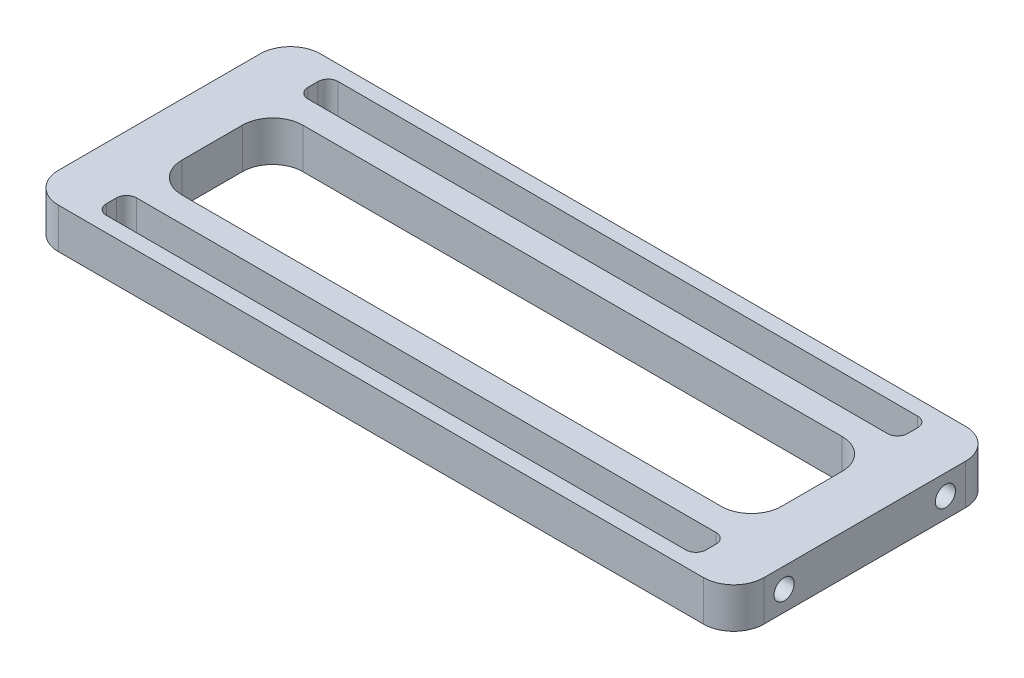
from build123d import *

# Parameters (mm, degrees)
BOSS_EXTRUDE1_DEPTH = 4
SKETCH2_R           = 1
CUT_EXTRUDE1_DEPTH  = 5


with BuildPart() as part:
    # Sketch1 → Boss-Extrude1 (new body)
    with BuildSketch(Plane(origin=(0, 0, 0), x_dir=(1, 0, 0), z_dir=(0, 1, 0))):
        with BuildLine():
            Line((-32, -13), (32, -13))
            ThreePointArc((32, -13), (34.121320344, -12.121320344), (35, -10))
            Line((35, -10), (35, 10))
            ThreePointArc((35, 10), (34.121320344, 12.121320344), (32, 13))
            Line((32, 13), (-32, 13))
            ThreePointArc((-32, 13), (-34.121320344, 12.121320344), (-35, 10))
            Line((-35, 10), (-35, -10))
            ThreePointArc((-35, -10), (-34.121320344, -12.121320344), (-32, -13))
        make_face()
        with BuildLine():
            Line((-26.749817226, -6), (26.749817226, -6))
            ThreePointArc((26.749817226, -6), (28.871137569, -5.121320344), (29.749817226, -3))
            Line((29.749817226, -3), (29.749817226, 3))
            ThreePointArc((29.749817226, 3), (28.871137569, 5.121320344), (26.749817226, 6))
            Line((26.749817226, 6), (-26.749817226, 6))
            ThreePointArc((-26.749817226, 6), (-28.871137569, 5.121320344), (-29.749817226, 3))
            Line((-29.749817226, 3), (-29.749817226, -3))
            ThreePointArc((-29.749817226, -3), (-28.871137569, -5.121320344), (-26.749817226, -6))
        make_face(mode=Mode.SUBTRACT)
        with BuildLine():
            Line((-28.749817226, 11.5), (28.749817226, 11.5))
            ThreePointArc((28.749817226, 11.5), (29.456924007, 11.207106781), (29.749817226, 10.5))
            Line((29.749817226, 10.5), (29.749817226, 9.5))
            ThreePointArc((29.749817226, 9.5), (29.456924007, 8.792893219), (28.749817226, 8.5))
            Line((28.749817226, 8.5), (-28.749817226, 8.5))
            ThreePointArc((-28.749817226, 8.5), (-29.456924007, 8.792893219), (-29.749817226, 9.5))
            Line((-29.749817226, 9.5), (-29.749817226, 10.5))
            ThreePointArc((-29.749817226, 10.5), (-29.456924007, 11.207106781), (-28.749817226, 11.5))
        make_face(mode=Mode.SUBTRACT)
        with BuildLine():
            Line((-29.749817226, -10.5), (-29.749817226, -9.5))
            ThreePointArc((-29.749817226, -9.5), (-29.456924007, -8.792893219), (-28.749817226, -8.5))
            Line((-28.749817226, -8.5), (28.749817226, -8.5))
            ThreePointArc((28.749817226, -8.5), (29.456924007, -8.792893219), (29.749817226, -9.5))
            Line((29.749817226, -9.5), (29.749817226, -10.5))
            ThreePointArc((29.749817226, -10.5), (29.456924007, -11.207106781), (28.749817226, -11.5))
            Line((28.749817226, -11.5), (-28.749817226, -11.5))
            ThreePointArc((-28.749817226, -11.5), (-29.456924007, -11.207106781), (-29.749817226, -10.5))
        make_face(mode=Mode.SUBTRACT)
    extrude(amount=BOSS_EXTRUDE1_DEPTH)

    # Sketch2 → Cut-Extrude1 (cut)
    with BuildSketch(Plane(origin=(35, 0, 0), x_dir=(0, 0, -1), z_dir=(1, 0, 0))):
        with Locations((-8, 2)):
            Circle(SKETCH2_R)
        with Locations((8, 2)):
            Circle(SKETCH2_R)
    extrude(amount=-CUT_EXTRUDE1_DEPTH, mode=Mode.SUBTRACT)


solid = part.part
